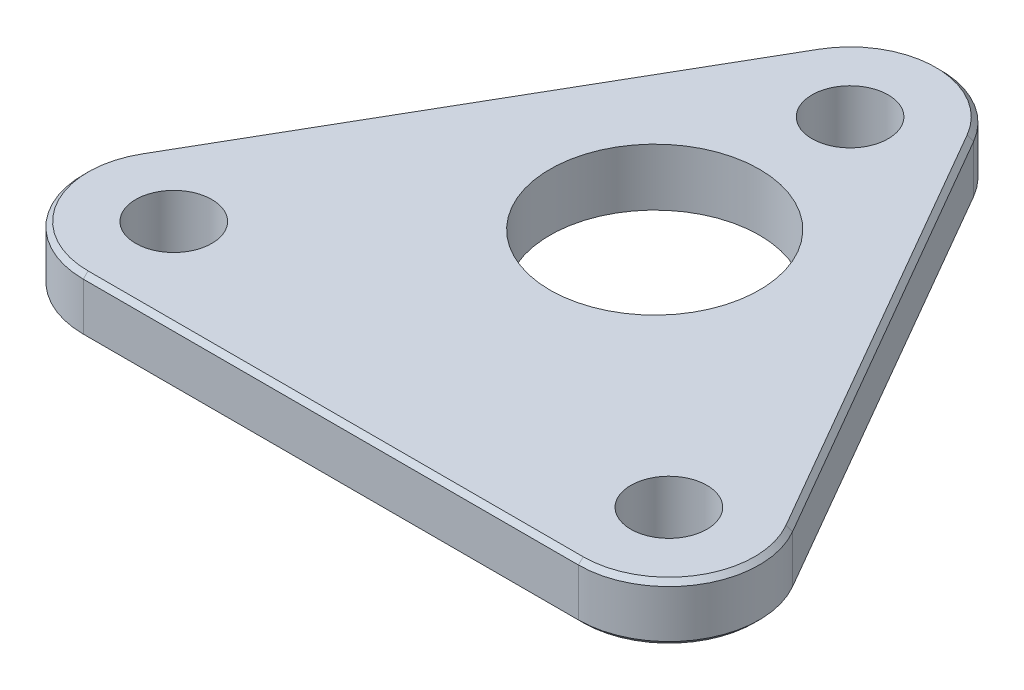
from build123d import *

# Parameters (mm, degrees)
SKETCH_1_R          = 9.5
SKETCH_1_R_2        = 4
EXTRUDE_1_DEPTH     = 6
CHAMFER_1_SIZE      = 0.5
CUT_EXTRUDE_1_REACH = 8
SKETCH_3_R          = 15
SKETCH_4_R          = 15
SKETCH_4_R_2        = 13
EXTRUDE_2_DEPTH     = 6
SKETCH_5_R          = 13
SKETCH_5_R_2        = 11
EXTRUDE_3_DEPTH     = 6


with BuildPart() as part:
    # ｽｹｯﾁ1 → ﾎﾞｽ - 押し出し1 (new body)
    with BuildSketch(Plane(origin=(0, 0, 0), x_dir=(1, 0, 0), z_dir=(0, 1, 0))):
        with BuildLine():
            ThreePointArc((9.5, 30.022213998), (-2.458780928, 20.845918648), (-8.227241336, 34.772213998))
            Line((-8.227241336, 34.772213998), (-34.227241336, -10.261106999))
            ThreePointArc((-34.227241336, -10.261106999), (-23.541219072, -5.834811649), (-16.5, -15.011106999))
            ThreePointArc((-16.5, -15.011106999), (-19.282485579, -21.72862142), (-26, -24.511106999))
            Line((-26, -24.511106999), (26, -24.511106999))
            ThreePointArc((26, -24.511106999), (17.772758664, -10.261106999), (34.227241336, -10.261106999))
            Line((34.227241336, -10.261106999), (8.227241336, 34.772213998))
            ThreePointArc((8.227241336, 34.772213998), (9.17629535, 32.480994926), (9.5, 30.022213998))
        make_face()
        with Locations((-26, -15.011106999)):
            Circle(SKETCH_1_R)
        with Locations((-26, -15.011106999)):
            Circle(SKETCH_1_R_2, mode=Mode.SUBTRACT)
        with Locations((26, -15.011106999)):
            Circle(SKETCH_1_R)
        with Locations((26, -15.011106999)):
            Circle(SKETCH_1_R_2, mode=Mode.SUBTRACT)
        with Locations((0, 30.022213998)):
            Circle(SKETCH_1_R)
        with Locations((0, 30.022213998)):
            Circle(SKETCH_1_R_2, mode=Mode.SUBTRACT)
    extrude(amount=EXTRUDE_1_DEPTH)

    # 面取り1
    chamfer_1_edges = [part.edges().sort_by_distance(p)[0] for p in [
        (-34.227241336, 6, 19.761106999),
        (0, 0, -39.522213998),
        (21.227241336, 0, -12.255553499),
        (34.227241336, 0, 19.761106999),
        (0, 0, 24.511106999),
        (-34.227241336, 0, 19.761106999),
        (-21.227241336, 0, -12.255553499),
        (0, 6, 24.511106999),
        (34.227241336, 6, 19.761106999),
        (21.227241336, 6, -12.255553499),
        (0, 6, -39.522213998),
        (-21.227241336, 6, -12.255553499),
    ]]
    chamfer(chamfer_1_edges, length=CHAMFER_1_SIZE)

    # ｽｹｯﾁ3 → ｶｯﾄ - 押し出し1 (cut, up to next)
    with BuildSketch(Plane.XZ, mode=Mode.PRIVATE) as cut_extrude_1_sk1:
        with Locations((0, -9.5)):
            Circle(SKETCH_3_R)
    cut_extrude_1_tool1 = extrude(cut_extrude_1_sk1.sketch, amount=-CUT_EXTRUDE_1_REACH, mode=Mode.PRIVATE) & part.part
    add(cut_extrude_1_tool1.solids().sort_by_distance((0, 0, -9.5))[0], mode=Mode.SUBTRACT)

    # ｽｹｯﾁ4 → ﾎﾞｽ - 押し出し2 (add)
    with BuildSketch(Plane.XZ):
        with Locations((0, -9.5)):
            Circle(SKETCH_4_R)
        with Locations((0, -9.5)):
            Circle(SKETCH_4_R_2, mode=Mode.SUBTRACT)
    extrude(amount=-EXTRUDE_2_DEPTH)

    # ｽｹｯﾁ5 → ﾎﾞｽ - 押し出し3 (add)
    with BuildSketch(Plane.XZ):
        with Locations((0, -9.5)):
            Circle(SKETCH_5_R)
        with Locations((0, -9.5)):
            Circle(SKETCH_5_R_2, mode=Mode.SUBTRACT)
    extrude(amount=-EXTRUDE_3_DEPTH)


solid = part.part
